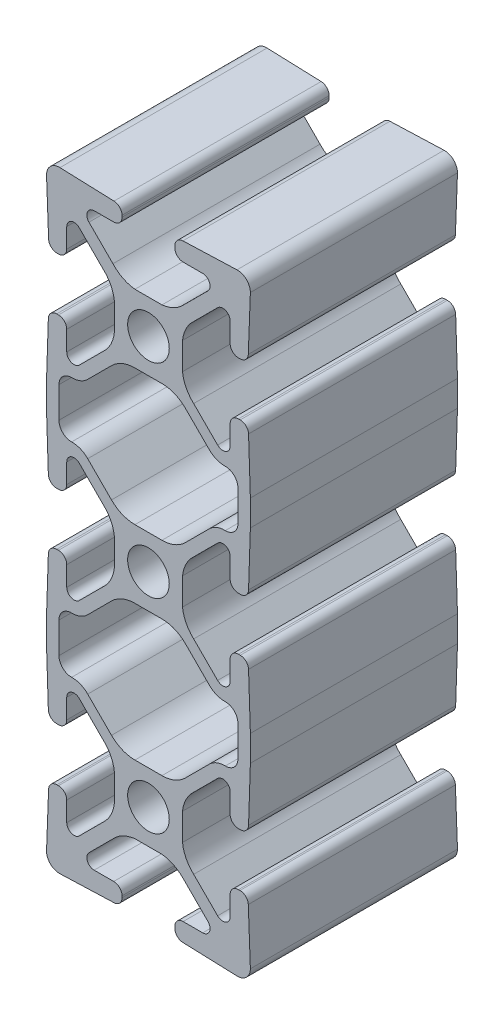
from build123d import *

# Parameters (mm, degrees)
SKETCH1_R      = 2.552699952
EXTRUDE1_DEPTH = 25.4


with BuildPart() as part:
    # Sketch1 → Extrude1 (new body)
    with BuildSketch(Plane.XY):
        with BuildLine():
            Line((-12.499999765, 35.912499325), (-12.499999765, 39.087499265))
            Line((-12.499999765, 39.087499265), (-12.277278698, 45.780048565))
            ThreePointArc((-12.277278698, 45.780048565), (-11.966958292, 46.477737471), (-11.258353132, 46.762249846))
            Line((-11.258353132, 46.762249846), (-11.035999792, 46.761486548))
            ThreePointArc((-11.035999792, 46.761486548), (-10.317579227, 46.463907006), (-10.019999685, 45.74548644))
            Line((-10.019999685, 45.74548644), (-10.019999931, 43.34250371))
            ThreePointArc((-10.019999931, 43.34250371), (-9.464416196, 42.511012537), (-8.483605576, 42.706105808))
            Line((-8.483605576, 42.706105808), (-5.545081932, 45.644613578))
            ThreePointArc((-5.545081932, 45.644613578), (-4.614735711, 46.867960778), (-4.177987221, 48.341518791))
            Line((-4.177987221, 48.341518791), (-4.177987221, 51.658479329))
            ThreePointArc((-4.177987221, 51.658479329), (-4.614735711, 53.132037342), (-5.545081932, 54.355384541))
            Line((-5.545081932, 54.355384541), (-8.483605576, 57.293892311))
            ThreePointArc((-8.483605576, 57.293892311), (-9.464416196, 57.488985582), (-10.019999931, 56.657494409))
            Line((-10.019999931, 56.657494409), (-10.019999685, 54.25451168))
            ThreePointArc((-10.019999685, 54.25451168), (-10.317579227, 53.536091114), (-11.035999792, 53.238511572))
            Line((-11.035999792, 53.238511572), (-11.226349864, 53.237858135))
            ThreePointArc((-11.226349864, 53.237858135), (-11.933208752, 53.520691189), (-12.24510272, 54.215217054))
            Line((-12.24510272, 54.215217054), (-12.499999765, 60.913484814))
            ThreePointArc((-12.499999765, 60.913484814), (-12.014686132, 62.056000212), (-10.855475092, 62.499960259))
            Line((-10.855475092, 62.499960259), (-4.22175692, 62.261516099))
            ThreePointArc((-4.22175692, 62.261516099), (-3.524602107, 61.952787993), (-3.238512512, 61.246041488))
            Line((-3.238512512, 61.246041488), (-3.238512512, 61.035998852))
            ThreePointArc((-3.238512512, 61.035998852), (-3.536092054, 60.317578286), (-4.25451262, 60.019998744))
            Line((-4.25451262, 60.019998744), (-6.657495349, 60.019998991))
            ThreePointArc((-6.657495349, 60.019998991), (-7.488986523, 59.464415256), (-7.293893252, 58.483604636))
            Line((-7.293893252, 58.483604636), (-4.355385482, 55.545080992))
            ThreePointArc((-4.355385482, 55.545080992), (-3.132038282, 54.614734771), (-1.658480269, 54.177986281))
            Line((-1.658480269, 54.177986281), (1.658480269, 54.177986281))
            ThreePointArc((1.658480269, 54.177986281), (3.132038282, 54.614734771), (4.355385482, 55.545080992))
            Line((4.355385482, 55.545080992), (7.293893252, 58.483604636))
            ThreePointArc((7.293893252, 58.483604636), (7.488986523, 59.464415256), (6.657495349, 60.019998991))
            Line((6.657495349, 60.019998991), (4.25451262, 60.019998744))
            ThreePointArc((4.25451262, 60.019998744), (3.536092054, 60.317578286), (3.238512512, 61.035998852))
            Line((3.238512512, 61.035998852), (3.238512512, 61.246041488))
            ThreePointArc((3.238512512, 61.246041488), (3.524602107, 61.952787993), (4.22175692, 62.261516099))
            Line((4.22175692, 62.261516099), (10.855475092, 62.499960259))
            ThreePointArc((10.855475092, 62.499960259), (12.014686132, 62.056000212), (12.499999765, 60.913484814))
            Line((12.499999765, 60.913484814), (12.24510272, 54.215217054))
            ThreePointArc((12.24510272, 54.215217054), (11.933208752, 53.520691189), (11.226349864, 53.237858135))
            Line((11.226349864, 53.237858135), (11.035999792, 53.238511572))
            ThreePointArc((11.035999792, 53.238511572), (10.317579227, 53.536091114), (10.019999685, 54.25451168))
            Line((10.019999685, 54.25451168), (10.019999931, 56.657494409))
            ThreePointArc((10.019999931, 56.657494409), (9.464416196, 57.488985582), (8.483605576, 57.293892311))
            Line((8.483605576, 57.293892311), (5.545081932, 54.355384541))
            ThreePointArc((5.545081932, 54.355384541), (4.614735711, 53.132037342), (4.177987221, 51.658479329))
            Line((4.177987221, 51.658479329), (4.177987221, 48.341518791))
            ThreePointArc((4.177987221, 48.341518791), (4.614735711, 46.867960778), (5.545081932, 45.644613578))
            Line((5.545081932, 45.644613578), (8.483605576, 42.706105808))
            ThreePointArc((8.483605576, 42.706105808), (9.464416196, 42.511012537), (10.019999931, 43.34250371))
            Line((10.019999931, 43.34250371), (10.019999685, 45.74548644))
            ThreePointArc((10.019999685, 45.74548644), (10.317579227, 46.463907006), (11.035999792, 46.761486548))
            Line((11.035999792, 46.761486548), (11.258353132, 46.762249846))
            ThreePointArc((11.258353132, 46.762249846), (11.966958292, 46.477737471), (12.277278698, 45.780048565))
            Line((12.277278698, 45.780048565), (12.499999765, 39.087499265))
            Line((12.499999765, 39.087499265), (12.499999765, 35.912499325))
            Line((12.499999765, 35.912499325), (12.277278698, 29.219950025))
            ThreePointArc((12.277278698, 29.219950025), (11.966958292, 28.522261118), (11.258353132, 28.237748743))
            Line((11.258353132, 28.237748743), (11.035999792, 28.238512042))
            ThreePointArc((11.035999792, 28.238512042), (10.317579227, 28.536091584), (10.019999685, 29.25451215))
            Line((10.019999685, 29.25451215), (10.019999931, 31.657494879))
            ThreePointArc((10.019999931, 31.657494879), (9.464416196, 32.488986052), (8.483605576, 32.293892782))
            Line((8.483605576, 32.293892782), (5.545081932, 29.355385011))
            ThreePointArc((5.545081932, 29.355385011), (4.614735711, 28.132037812), (4.177987221, 26.658479799))
            Line((4.177987221, 26.658479799), (4.177987221, 23.341519261))
            ThreePointArc((4.177987221, 23.341519261), (4.614735711, 21.867961248), (5.545081932, 20.644614048))
            Line((5.545081932, 20.644614048), (8.483605576, 17.706106278))
            ThreePointArc((8.483605576, 17.706106278), (9.464416196, 17.511013007), (10.019999931, 18.34250418))
            Line((10.019999931, 18.34250418), (10.019999685, 20.74548691))
            ThreePointArc((10.019999685, 20.74548691), (10.317579227, 21.463907476), (11.035999792, 21.761487018))
            Line((11.035999792, 21.761487018), (11.258353132, 21.762250316))
            ThreePointArc((11.258353132, 21.762250316), (11.966958292, 21.477737942), (12.277278698, 20.780049035))
            Line((12.277278698, 20.780049035), (12.499999765, 14.087499735))
            Line((12.499999765, 14.087499735), (12.499999765, 10.912499795))
            Line((12.499999765, 10.912499795), (12.277278698, 4.219950495))
            ThreePointArc((12.277278698, 4.219950495), (11.966958292, 3.522261588), (11.258353132, 3.237749214))
            Line((11.258353132, 3.237749214), (11.035999792, 3.238512512))
            ThreePointArc((11.035999792, 3.238512512), (10.317579227, 3.536092054), (10.019999685, 4.25451262))
            Line((10.019999685, 4.25451262), (10.019999931, 6.657495349))
            ThreePointArc((10.019999931, 6.657495349), (9.464416196, 7.488986523), (8.483605576, 7.293893252))
            Line((8.483605576, 7.293893252), (5.545081932, 4.355385482))
            ThreePointArc((5.545081932, 4.355385482), (4.614735711, 3.132038282), (4.177987221, 1.658480269))
            Line((4.177987221, 1.658480269), (4.177987221, -1.658480269))
            ThreePointArc((4.177987221, -1.658480269), (4.614735711, -3.132038282), (5.545081932, -4.355385482))
            Line((5.545081932, -4.355385482), (8.483605576, -7.293893252))
            ThreePointArc((8.483605576, -7.293893252), (9.464416196, -7.488986523), (10.019999931, -6.657495349))
            Line((10.019999931, -6.657495349), (10.019999685, -4.25451262))
            ThreePointArc((10.019999685, -4.25451262), (10.317579227, -3.536092054), (11.035999792, -3.238512512))
            Line((11.035999792, -3.238512512), (11.226349864, -3.237859075))
            ThreePointArc((11.226349864, -3.237859075), (11.933208752, -3.520692129), (12.24510272, -4.215217994))
            Line((12.24510272, -4.215217994), (12.499999765, -10.913485754))
            ThreePointArc((12.499999765, -10.913485754), (12.014686132, -12.056001152), (10.855475092, -12.4999612))
            Line((10.855475092, -12.4999612), (4.22175692, -12.26151704))
            ThreePointArc((4.22175692, -12.26151704), (3.524602107, -11.952788933), (3.238512512, -11.246042429))
            Line((3.238512512, -11.246042429), (3.238512512, -11.035999792))
            ThreePointArc((3.238512512, -11.035999792), (3.536092054, -10.317579227), (4.25451262, -10.019999685))
            Line((4.25451262, -10.019999685), (6.657495349, -10.019999931))
            ThreePointArc((6.657495349, -10.019999931), (7.488986523, -9.464416196), (7.293893252, -8.483605576))
            Line((7.293893252, -8.483605576), (4.355385482, -5.545081932))
            ThreePointArc((4.355385482, -5.545081932), (3.132038282, -4.614735711), (1.658480269, -4.177987221))
            Line((1.658480269, -4.177987221), (-1.658480269, -4.177987221))
            ThreePointArc((-1.658480269, -4.177987221), (-3.132038282, -4.614735711), (-4.355385482, -5.545081932))
            Line((-4.355385482, -5.545081932), (-7.293893252, -8.483605576))
            ThreePointArc((-7.293893252, -8.483605576), (-7.488986523, -9.464416196), (-6.657495349, -10.019999931))
            Line((-6.657495349, -10.019999931), (-4.25451262, -10.019999685))
            ThreePointArc((-4.25451262, -10.019999685), (-3.536092054, -10.317579227), (-3.238512512, -11.035999792))
            Line((-3.238512512, -11.035999792), (-3.238512512, -11.246042429))
            ThreePointArc((-3.238512512, -11.246042429), (-3.524602107, -11.952788933), (-4.22175692, -12.26151704))
            Line((-4.22175692, -12.26151704), (-10.855475092, -12.4999612))
            ThreePointArc((-10.855475092, -12.4999612), (-12.014686132, -12.056001152), (-12.499999765, -10.913485754))
            Line((-12.499999765, -10.913485754), (-12.24510272, -4.215217994))
            ThreePointArc((-12.24510272, -4.215217994), (-11.933208752, -3.520692129), (-11.226349864, -3.237859075))
            Line((-11.226349864, -3.237859075), (-11.035999792, -3.238512512))
            ThreePointArc((-11.035999792, -3.238512512), (-10.317579227, -3.536092054), (-10.019999685, -4.25451262))
            Line((-10.019999685, -4.25451262), (-10.019999931, -6.657495349))
            ThreePointArc((-10.019999931, -6.657495349), (-9.464416196, -7.488986523), (-8.483605576, -7.293893252))
            Line((-8.483605576, -7.293893252), (-5.545081932, -4.355385482))
            ThreePointArc((-5.545081932, -4.355385482), (-4.614735711, -3.132038282), (-4.177987221, -1.658480269))
            Line((-4.177987221, -1.658480269), (-4.177987221, 1.658480269))
            ThreePointArc((-4.177987221, 1.658480269), (-4.614735711, 3.132038282), (-5.545081932, 4.355385482))
            Line((-5.545081932, 4.355385482), (-8.483605576, 7.293893252))
            ThreePointArc((-8.483605576, 7.293893252), (-9.464416196, 7.488986523), (-10.019999931, 6.657495349))
            Line((-10.019999931, 6.657495349), (-10.019999685, 4.25451262))
            ThreePointArc((-10.019999685, 4.25451262), (-10.317579227, 3.536092054), (-11.035999792, 3.238512512))
            Line((-11.035999792, 3.238512512), (-11.258353132, 3.237749214))
            ThreePointArc((-11.258353132, 3.237749214), (-11.966958292, 3.522261588), (-12.277278698, 4.219950495))
            Line((-12.277278698, 4.219950495), (-12.499999765, 10.912499795))
            Line((-12.499999765, 10.912499795), (-12.499999765, 14.087499735))
            Line((-12.499999765, 14.087499735), (-12.277278698, 20.780049035))
            ThreePointArc((-12.277278698, 20.780049035), (-11.966958292, 21.477737942), (-11.258353132, 21.762250316))
            Line((-11.258353132, 21.762250316), (-11.035999792, 21.761487018))
            ThreePointArc((-11.035999792, 21.761487018), (-10.317579227, 21.463907476), (-10.019999685, 20.74548691))
            Line((-10.019999685, 20.74548691), (-10.019999931, 18.34250418))
            ThreePointArc((-10.019999931, 18.34250418), (-9.464416196, 17.511013007), (-8.483605576, 17.706106278))
            Line((-8.483605576, 17.706106278), (-5.545081932, 20.644614048))
            ThreePointArc((-5.545081932, 20.644614048), (-4.614735711, 21.867961248), (-4.177987221, 23.341519261))
            Line((-4.177987221, 23.341519261), (-4.177987221, 26.658479799))
            ThreePointArc((-4.177987221, 26.658479799), (-4.614735711, 28.132037812), (-5.545081932, 29.355385011))
            Line((-5.545081932, 29.355385011), (-8.483605576, 32.293892782))
            ThreePointArc((-8.483605576, 32.293892782), (-9.464416196, 32.488986052), (-10.019999931, 31.657494879))
            Line((-10.019999931, 31.657494879), (-10.019999685, 29.25451215))
            ThreePointArc((-10.019999685, 29.25451215), (-10.317579227, 28.536091584), (-11.035999792, 28.238512042))
            Line((-11.035999792, 28.238512042), (-11.258353132, 28.237748743))
            ThreePointArc((-11.258353132, 28.237748743), (-11.966958292, 28.522261118), (-12.277278698, 29.219950025))
            Line((-12.277278698, 29.219950025), (-12.499999765, 35.912499325))
        make_face()
        Circle(SKETCH1_R, mode=Mode.SUBTRACT)
        with Locations((0, 24.99999953)):
            Circle(SKETCH1_R, mode=Mode.SUBTRACT)
        with Locations((0, 49.99999906)):
            Circle(SKETCH1_R, mode=Mode.SUBTRACT)
        with BuildLine():
            Line((-7.449420439, 41.714419795), (-4.532162174, 44.631693819))
            ThreePointArc((-4.532162174, 44.631693819), (-3.213705709, 45.512658264), (-1.658480269, 45.822011838))
            Line((-1.658480269, 45.822011838), (1.658480269, 45.822011838))
            ThreePointArc((1.658480269, 45.822011838), (3.213705709, 45.512658264), (4.532162174, 44.631693819))
            Line((4.532162174, 44.631693819), (7.449420439, 41.714419795))
            ThreePointArc((7.449420439, 41.714419795), (8.351141741, 41.110638205), (9.418419027, 40.914238846))
            ThreePointArc((9.418419027, 40.914238846), (10.5176918, 40.480047517), (10.975999794, 39.39060889))
            Line((10.975999794, 39.39060889), (10.975999794, 35.6093897))
            ThreePointArc((10.975999794, 35.6093897), (10.5176918, 34.519951073), (9.418419027, 34.085759744))
            ThreePointArc((9.418419027, 34.085759744), (8.351141741, 33.889360385), (7.449420439, 33.285578795))
            Line((7.449420439, 33.285578795), (4.532162174, 30.36830477))
            ThreePointArc((4.532162174, 30.36830477), (3.213705709, 29.487340325), (1.658480269, 29.177986751))
            Line((1.658480269, 29.177986751), (-1.658480269, 29.177986751))
            ThreePointArc((-1.658480269, 29.177986751), (-3.213705709, 29.487340325), (-4.532162174, 30.36830477))
            Line((-4.532162174, 30.36830477), (-7.449420439, 33.285578795))
            ThreePointArc((-7.449420439, 33.285578795), (-8.351141741, 33.889360385), (-9.418419027, 34.085759744))
            ThreePointArc((-9.418419027, 34.085759744), (-10.5176918, 34.519951073), (-10.975999794, 35.6093897))
            Line((-10.975999794, 35.6093897), (-10.975999794, 39.39060889))
            ThreePointArc((-10.975999794, 39.39060889), (-10.5176918, 40.480047517), (-9.418419027, 40.914238846))
            ThreePointArc((-9.418419027, 40.914238846), (-8.351141741, 41.110638205), (-7.449420439, 41.714419795))
        make_face(mode=Mode.SUBTRACT)
        with BuildLine():
            Line((10.975999794, 14.39060936), (10.975999794, 10.60939017))
            ThreePointArc((10.975999794, 10.60939017), (10.5176918, 9.519951543), (9.418419027, 9.085760214))
            ThreePointArc((9.418419027, 9.085760214), (8.351141741, 8.889360855), (7.449420439, 8.285579265))
            Line((7.449420439, 8.285579265), (4.532162174, 5.36830524))
            ThreePointArc((4.532162174, 5.36830524), (3.213705709, 4.487340795), (1.658480269, 4.177987221))
            Line((1.658480269, 4.177987221), (-1.658480269, 4.177987221))
            ThreePointArc((-1.658480269, 4.177987221), (-3.213705709, 4.487340795), (-4.532162174, 5.36830524))
            Line((-4.532162174, 5.36830524), (-7.449420439, 8.285579265))
            ThreePointArc((-7.449420439, 8.285579265), (-8.351141741, 8.889360855), (-9.418419027, 9.085760214))
            ThreePointArc((-9.418419027, 9.085760214), (-10.5176918, 9.519951543), (-10.975999794, 10.60939017))
            Line((-10.975999794, 10.60939017), (-10.975999794, 14.39060936))
            ThreePointArc((-10.975999794, 14.39060936), (-10.5176918, 15.480047987), (-9.418419027, 15.914239316))
            ThreePointArc((-9.418419027, 15.914239316), (-8.351141741, 16.110638675), (-7.449420439, 16.714420265))
            Line((-7.449420439, 16.714420265), (-4.532162174, 19.63169429))
            ThreePointArc((-4.532162174, 19.63169429), (-3.213705709, 20.512658734), (-1.658480269, 20.822012308))
            Line((-1.658480269, 20.822012308), (1.658480269, 20.822012308))
            ThreePointArc((1.658480269, 20.822012308), (3.213705709, 20.512658734), (4.532162174, 19.63169429))
            Line((4.532162174, 19.63169429), (7.449420439, 16.714420265))
            ThreePointArc((7.449420439, 16.714420265), (8.351141741, 16.110638675), (9.418419027, 15.914239316))
            ThreePointArc((9.418419027, 15.914239316), (10.5176918, 15.480047987), (10.975999794, 14.39060936))
        make_face(mode=Mode.SUBTRACT)
    extrude(amount=EXTRUDE1_DEPTH)


solid = part.part
